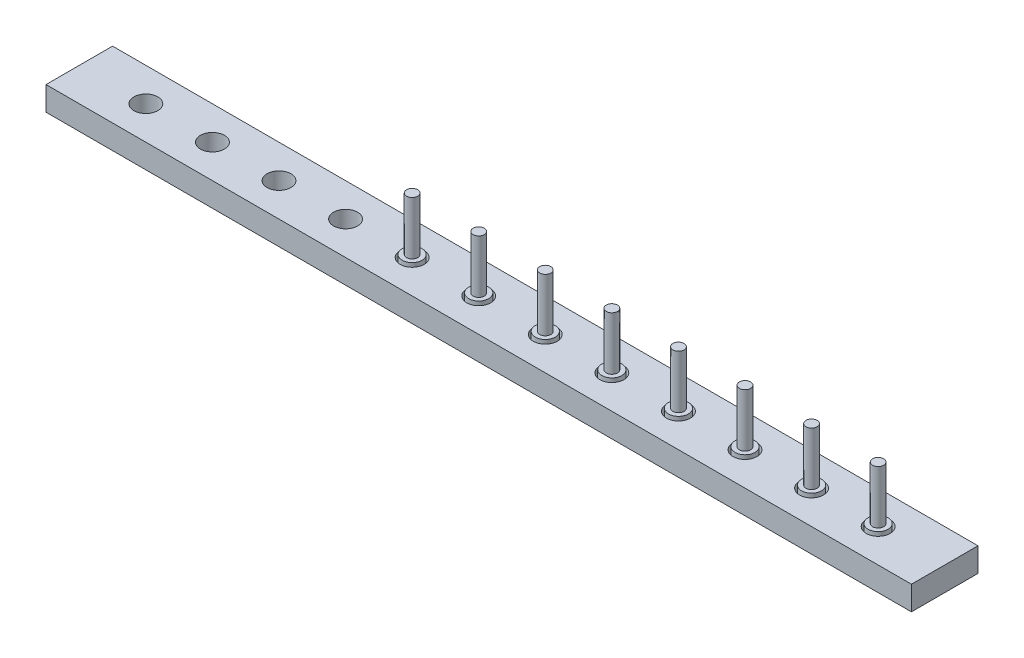
from build123d import *

# Parameters (mm, degrees)
SKETCH1_W             = 3250
SKETCH1_H             = 250
BOSS_EXTRUDE1_DEPTH   = 90
SKETCH2_R             = 45
CUT_EXTRUDE1_DEPTH    = 100
SKETCH3_R             = 37.5
BOSS_EXTRUDE2_DEPTH   = 100
BOSS_EXTRUDE2_2_DEPTH = 100
BOSS_EXTRUDE2_3_DEPTH = 100
BOSS_EXTRUDE2_4_DEPTH = 100
BOSS_EXTRUDE2_5_DEPTH = 100
BOSS_EXTRUDE2_6_DEPTH = 100
BOSS_EXTRUDE2_7_DEPTH = 100
BOSS_EXTRUDE2_8_DEPTH = 100
SKETCH5_R             = 21
BOSS_EXTRUDE3_DEPTH   = 200


with BuildPart() as part:
    # Sketch1 → Boss-Extrude1 (new body)
    with BuildSketch(Plane(origin=(0, 0, 0), x_dir=(1, 0, 0), z_dir=(0, 1, 0))):
        Rectangle(SKETCH1_W, SKETCH1_H)
    extrude(amount=BOSS_EXTRUDE1_DEPTH)

    # Sketch2 → Cut-Extrude1 (cut)
    with BuildSketch(Plane(origin=(0, 90, 0), x_dir=(1, 0, 0), z_dir=(0, 1, 0))):
        with Locations((-1375, 0)):
            Circle(SKETCH2_R)
        with Locations((-1125, 0)):
            Circle(SKETCH2_R)
        with Locations((-875, 0)):
            Circle(SKETCH2_R)
        with Locations((-625, 0)):
            Circle(SKETCH2_R)
        with Locations((-375, 0)):
            Circle(SKETCH2_R)
        with Locations((-125, 0)):
            Circle(SKETCH2_R)
        with Locations((125, 0)):
            Circle(SKETCH2_R)
        with Locations((375, 0)):
            Circle(SKETCH2_R)
        with Locations((625, 0)):
            Circle(SKETCH2_R)
        with Locations((875, 0)):
            Circle(SKETCH2_R)
        with Locations((1125, 0)):
            Circle(SKETCH2_R)
        with Locations((1375, 0)):
            Circle(SKETCH2_R)
    extrude(amount=-CUT_EXTRUDE1_DEPTH, mode=Mode.SUBTRACT)


with BuildPart() as body_2:
    # Sketch3 → Boss-Extrude2 (new body)
    with BuildSketch(Plane.XZ):
        with Locations((-375, 0)):
            Circle(SKETCH3_R)
    extrude(amount=-BOSS_EXTRUDE2_DEPTH)



with BuildPart() as body_3:
    # Sketch3 → Boss-Extrude2 2 (new body)
    with BuildSketch(Plane.XZ):
        with Locations((-125, 0)):
            Circle(SKETCH3_R)
    extrude(amount=-BOSS_EXTRUDE2_2_DEPTH)


with BuildPart() as body_4:
    # Sketch3 → Boss-Extrude2 3 (new body)
    with BuildSketch(Plane.XZ):
        with Locations((125, 0)):
            Circle(SKETCH3_R)
    extrude(amount=-BOSS_EXTRUDE2_3_DEPTH)


with BuildPart() as body_5:
    # Sketch3 → Boss-Extrude2 4 (new body)
    with BuildSketch(Plane.XZ):
        with Locations((375, 0)):
            Circle(SKETCH3_R)
    extrude(amount=-BOSS_EXTRUDE2_4_DEPTH)


with BuildPart() as body_6:
    # Sketch3 → Boss-Extrude2 5 (new body)
    with BuildSketch(Plane.XZ):
        with Locations((625, 0)):
            Circle(SKETCH3_R)
    extrude(amount=-BOSS_EXTRUDE2_5_DEPTH)


with BuildPart() as body_7:
    # Sketch3 → Boss-Extrude2 6 (new body)
    with BuildSketch(Plane.XZ):
        with Locations((875, 0)):
            Circle(SKETCH3_R)
    extrude(amount=-BOSS_EXTRUDE2_6_DEPTH)


with BuildPart() as body_8:
    # Sketch3 → Boss-Extrude2 7 (new body)
    with BuildSketch(Plane.XZ):
        with Locations((1125, 0)):
            Circle(SKETCH3_R)
    extrude(amount=-BOSS_EXTRUDE2_7_DEPTH)


with BuildPart() as body_9:
    # Sketch3 → Boss-Extrude2 8 (new body)
    with BuildSketch(Plane.XZ):
        with Locations((1375, 0)):
            Circle(SKETCH3_R)
    extrude(amount=-BOSS_EXTRUDE2_8_DEPTH)


with BuildPart() as body_2_1:
    add(body_2.part)

    add(body_3.part)  # Boss-Extrude3 merges body 3

    add(body_4.part)  # Boss-Extrude3 merges body 4

    add(body_5.part)  # Boss-Extrude3 merges body 5

    add(body_6.part)  # Boss-Extrude3 merges body 6

    add(body_7.part)  # Boss-Extrude3 merges body 7

    add(body_8.part)  # Boss-Extrude3 merges body 8

    add(body_9.part)  # Boss-Extrude3 merges body 9
    # Sketch5 → Boss-Extrude3 (add)
    with BuildSketch(Plane(origin=(0, 100, 0), x_dir=(1, 0, 0), z_dir=(0, 1, 0))):
        with Locations((-375, 0)):
            Circle(SKETCH5_R)
        with Locations((-125, 0)):
            Circle(SKETCH5_R)
        with Locations((125, 0)):
            Circle(SKETCH5_R)
        with Locations((375, 0)):
            Circle(SKETCH5_R)
        with Locations((625, 0)):
            Circle(SKETCH5_R)
        with Locations((875, 0)):
            Circle(SKETCH5_R)
        with Locations((1125, 0)):
            Circle(SKETCH5_R)
        with Locations((1375, 0)):
            Circle(SKETCH5_R)
    extrude(amount=BOSS_EXTRUDE3_DEPTH)


solid = Compound([part.part, body_2_1.part])
